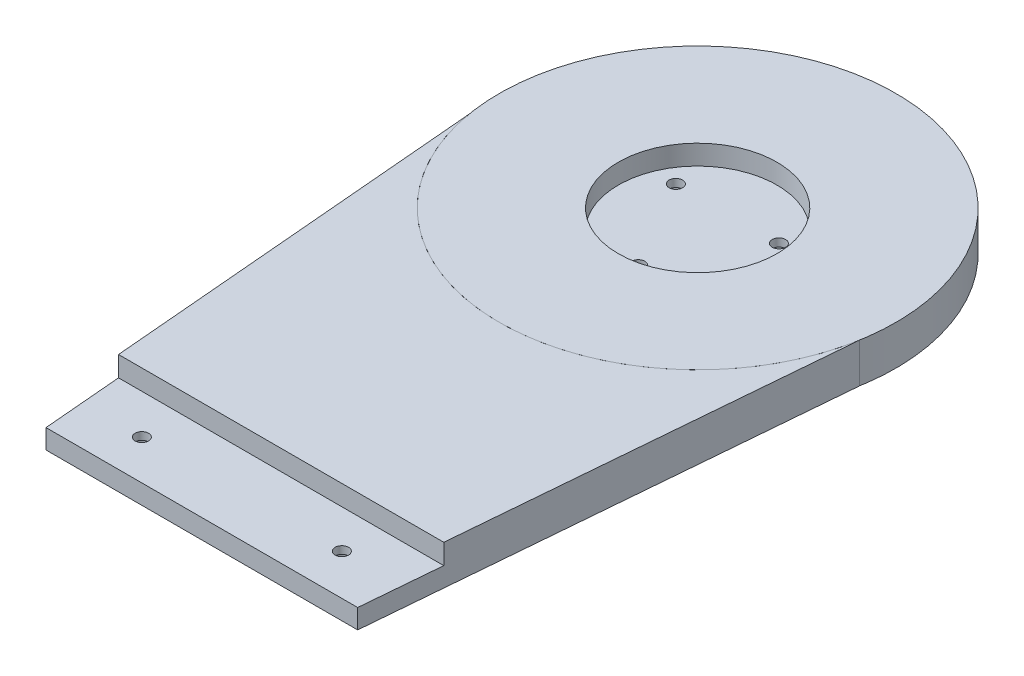
from build123d import *

# Parameters (mm, degrees)
SKETCH1_R           = 50
BOSS_EXTRUDE1_DEPTH = 10
SKETCH2_R           = 20
CUT_EXTRUDE1_DEPTH  = 5
CUT_EXTRUDE6_DEPTH  = 3
SKETCH8_R           = 1.7
CUT_EXTRUDE7_DEPTH  = 10
BOSS_EXTRUDE3_DEPTH = 10
SKETCH10_W          = 21
SKETCH10_H          = 41
CUT_EXTRUDE8_DEPTH  = 10
SKETCH11_W          = 21
SKETCH11_H          = 6.5
CUT_EXTRUDE9_DEPTH  = 1.5
SKETCH12_R          = 1.7
CUT_EXTRUDE10_DEPTH = 9
CUT_EXTRUDE11_DEPTH = 10
SKETCH14_W          = 121.865884167
SKETCH14_H          = 250
CUT_EXTRUDE12_DEPTH = 10
SKETCH18_R          = 1.7
CUT_EXTRUDE16_DEPTH = 5.1
SKETCH18_3_R        = 1.7
CUT_EXTRUDE17_DEPTH = 10
SKETCH19_R          = 3
CUT_EXTRUDE18_DEPTH = 3


with BuildPart() as part:
    # Sketch1 → Boss-Extrude1 (new body)
    with BuildSketch(Plane(origin=(0, 0, 0), x_dir=(1, 0, 0), z_dir=(0, 1, 0))):
        Circle(SKETCH1_R)
    extrude(amount=BOSS_EXTRUDE1_DEPTH)

    # Sketch2 → Cut-Extrude1 (cut)
    with BuildSketch(Plane(origin=(0, 10, 0), x_dir=(1, 0, 0), z_dir=(0, 1, 0))):
        Circle(SKETCH2_R)
    extrude(amount=-CUT_EXTRUDE1_DEPTH, mode=Mode.SUBTRACT)

    # Sketch7 → Cut-Extrude6 (cut)
    with BuildSketch(Plane.XZ):
        Polygon((12.990381057, -4.209103466), (10.140381057, -5.854551733), (10.140381057, -9.145448267), (12.990381057, -10.790896534), (15.840381057, -9.145448267), (15.840381057, -5.854551733), align=None)
        Polygon((-12.990381057, -4.209103466), (-15.840381057, -5.854551733), (-15.840381057, -9.145448267), (-12.990381057, -10.790896534), (-10.140381057, -9.145448267), (-10.140381057, -5.854551733), align=None)
        Polygon((-2.85, 16.645448267), (-2.85, 13.354551733), (0, 11.709103466), (2.85, 13.354551733), (2.85, 16.645448267), (0, 18.290896534), align=None)
    extrude(amount=-CUT_EXTRUDE6_DEPTH, mode=Mode.SUBTRACT)

    # Sketch8 → Cut-Extrude7 (cut)
    with BuildSketch(Plane.XZ):
        with Locations((0, 15)):
            Circle(SKETCH8_R)
        with Locations((12.990381057, -7.5)):
            Circle(SKETCH8_R)
        with Locations((-12.990381057, -7.5)):
            Circle(SKETCH8_R)
    extrude(amount=-CUT_EXTRUDE7_DEPTH, mode=Mode.SUBTRACT)


with BuildPart() as body_2:
    # Sketch9 → Boss-Extrude3 (new body)
    with BuildSketch(Plane.XZ):
        with BuildLine():
            Line((-50, 350), (-50, 0))
            ThreePointArc((-50, 0), (0, 50), (50, 0))
            Line((50, 0), (50, 350))
            Line((50, 350), (-50, 350))
        make_face()
    extrude(amount=-BOSS_EXTRUDE3_DEPTH)

    # Sketch10 → Cut-Extrude8 (cut)
    with BuildSketch(Plane.XZ):
        with Locations((0, 319.5)):
            Rectangle(SKETCH10_W, SKETCH10_H)
    extrude(amount=-CUT_EXTRUDE8_DEPTH, mode=Mode.SUBTRACT)

    # Sketch11 → Cut-Extrude9 (cut)
    with BuildSketch(Plane.XZ):
        with Locations((0, 295.75)):
            Rectangle(SKETCH11_W, SKETCH11_H)
        with Locations((0, 343.25)):
            Rectangle(SKETCH11_W, SKETCH11_H)
    extrude(amount=-CUT_EXTRUDE9_DEPTH, mode=Mode.SUBTRACT)

    # Sketch12 → Cut-Extrude10 (cut)
    with BuildSketch(Plane.XZ.offset(-1.5)):
        with Locations((-5, 343.75)):
            Circle(SKETCH12_R)
        with Locations((5, 343.75)):
            Circle(SKETCH12_R)
        with Locations((-5, 295.25)):
            Circle(SKETCH12_R)
        with Locations((5, 295.25)):
            Circle(SKETCH12_R)
    extrude(amount=-CUT_EXTRUDE10_DEPTH, mode=Mode.SUBTRACT)

    # Sketch13 → Cut-Extrude11 (cut)
    with BuildSketch(Plane.XZ):
        with BuildLine():
            Line((-50, 350), (-50, 0))
            ThreePointArc((-50, 0), (-49.817332452, 4.270057067), (-49.270664506, 8.5089141))
            Line((-49.270664506, 8.5089141), (-20, 350))
            Line((-20, 350), (-50, 350))
        make_face()
        with BuildLine():
            Line((20, 350), (49.270664506, 8.5089141))
            ThreePointArc((49.270664506, 8.5089141), (49.817332452, 4.270057067), (50, 0))
            Line((50, 0), (50, 350))
            Line((50, 350), (20, 350))
        make_face()
    extrude(amount=-CUT_EXTRUDE11_DEPTH, mode=Mode.SUBTRACT)

    # Sketch14 → Cut-Extrude12 (cut)
    with BuildSketch(Plane.XZ):
        with Locations((-3.231493741, 250)):
            Rectangle(SKETCH14_W, SKETCH14_H)
    extrude(amount=-CUT_EXTRUDE12_DEPTH, mode=Mode.SUBTRACT)

    # Sketch18 → Cut-Extrude16 (cut)
    with BuildSketch(Plane(origin=(0, 10, 0), x_dir=(1, 0, 0), z_dir=(0, 1, 0))):
        Polygon((41, -105), (-41, -105), (-39.285714286, -125), (39.285714286, -125), align=None)
        with Locations((-25.122464826, -115)):
            Circle(SKETCH18_R, mode=Mode.SUBTRACT)
        with Locations((24.998120775, -114.693099561)):
            Circle(SKETCH18_R, mode=Mode.SUBTRACT)
    extrude(amount=-CUT_EXTRUDE16_DEPTH, mode=Mode.SUBTRACT)

    # Sketch18_3 → Cut-Extrude17 (cut)
    with BuildSketch(Plane(origin=(0, 10, 0), x_dir=(1, 0, 0), z_dir=(0, 1, 0))):
        with Locations((-25.122464826, -115)):
            Circle(SKETCH18_3_R)
        with Locations((24.998120775, -114.693099561)):
            Circle(SKETCH18_3_R)
    extrude(amount=-CUT_EXTRUDE17_DEPTH, mode=Mode.SUBTRACT)

    # Sketch19 → Cut-Extrude18 (cut)
    with BuildSketch(Plane.XZ):
        with Locations((-25.122464826, 115)):
            Circle(SKETCH19_R)
        with Locations((24.998120775, 114.693099561)):
            Circle(SKETCH19_R)
    extrude(amount=-CUT_EXTRUDE18_DEPTH, mode=Mode.SUBTRACT)


solid = Compound([part.part, body_2.part])
